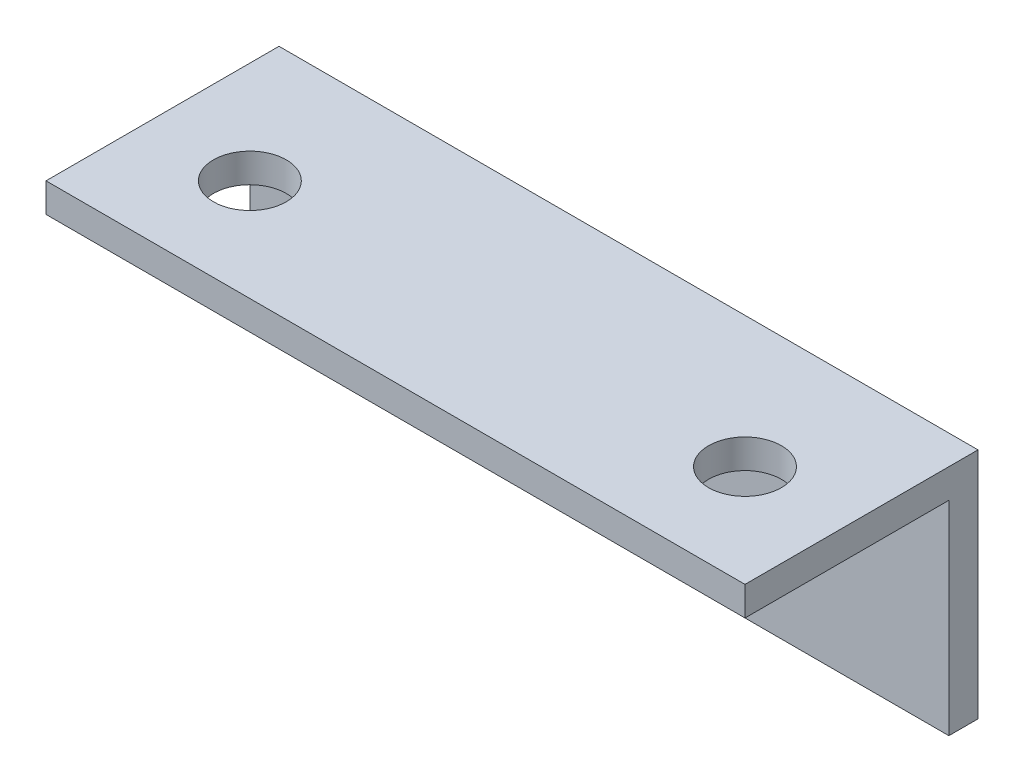
from build123d import *

# Parameters (mm, degrees)
BOSS_EXTRUDE2_DEPTH                = 38.1
F_5_16_0_3125_DIAMETER_HOLE1_D     = 7.9375
F_5_16_0_3125_DIAMETER_HOLE1_DEPTH = 3.175


with BuildPart() as part:
    # Sketch1 → Boss-Extrude2 (new body, symmetric)
    with BuildSketch(Plane(origin=(0, 0, 0), x_dir=(0, 0, -1), z_dir=(1, 0, 0))):
        Polygon((0, 0), (-25.4, 0), (-25.4, -3.175), (-3.175, -3.175), (-3.175, -25.4), (0, -25.4), align=None)
    extrude(amount=BOSS_EXTRUDE2_DEPTH, both=True)

    # 5/16 (0.3125) Diameter Hole1
    with Locations(Plane(origin=(0, 0, 0), x_dir=(1, 0, 0), z_dir=(0, 1, 0))):
        with Locations((-26.9875, -14.2875), (26.9875, -14.2875)):
            Hole(F_5_16_0_3125_DIAMETER_HOLE1_D / 2, depth=F_5_16_0_3125_DIAMETER_HOLE1_DEPTH)


solid = part.part
